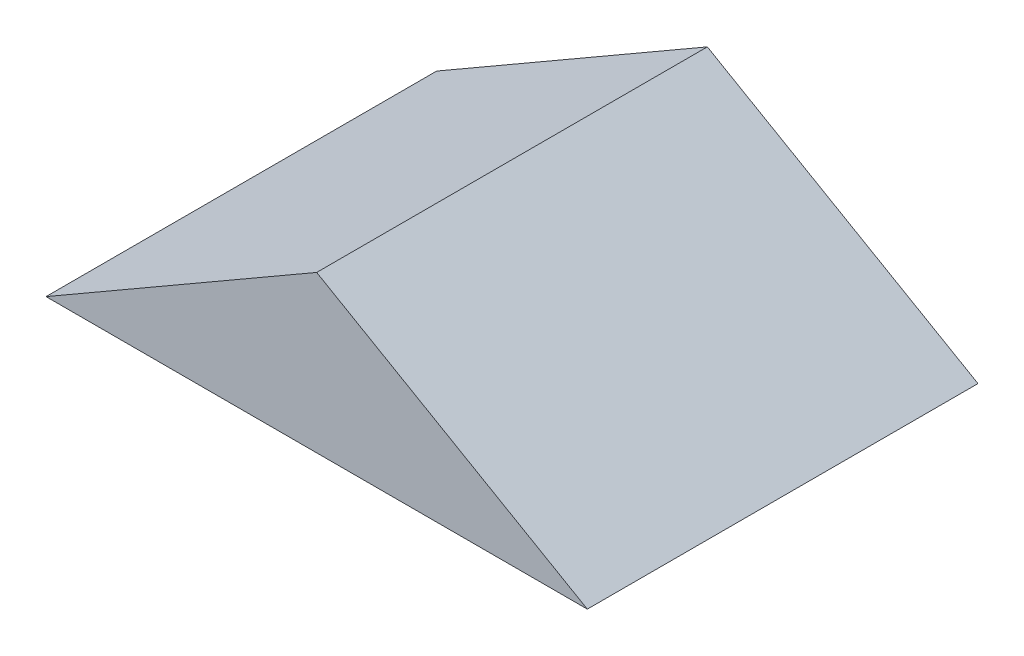
from build123d import *

# Parameters (mm, degrees)
BOSS_EXTRUDE1_DEPTH = 12.7


with BuildPart() as part:
    # Sketch1 → Boss-Extrude1 (new body)
    with BuildSketch(Plane.XY):
        Polygon((-8.798818102, 0), (8.798818102, 0), (0, 5.08), align=None)
    extrude(amount=BOSS_EXTRUDE1_DEPTH)


solid = part.part
